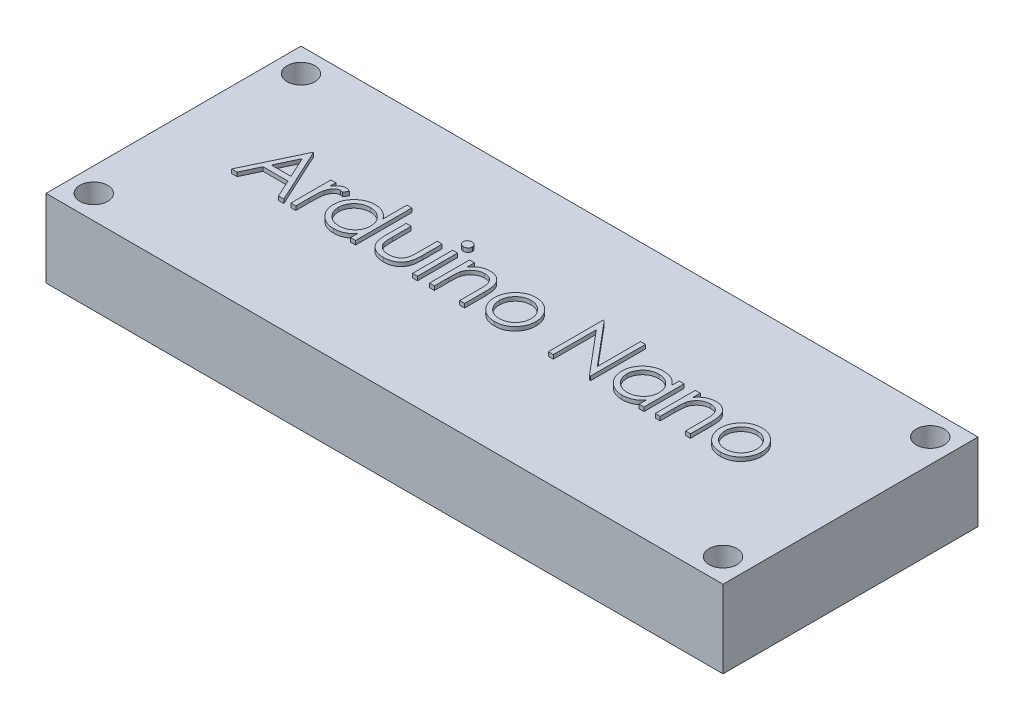
from build123d import *

# Parameters (mm, degrees)
SKETCH1_W           = 43.18
SKETCH1_H           = 16.26414524
SKETCH1_R           = 0.889
BOSS_EXTRUDE1_DEPTH = 4.953
SKETCH2_W           = 0.314102565
SKETCH2_H           = 2.557692308
BOSS_EXTRUDE2_DEPTH = 0.254


with BuildPart() as part:
    # Sketch1 → Boss-Extrude1 (new body)
    with BuildSketch(Plane(origin=(0, 0, 0), x_dir=(1, 0, 0), z_dir=(0, 1, 0))):
        Rectangle(SKETCH1_W, SKETCH1_H)
        with Locations((-20.066, 6.60807262)):
            Circle(SKETCH1_R, mode=Mode.SUBTRACT)
        with Locations((20.066, 6.60807262)):
            Circle(SKETCH1_R, mode=Mode.SUBTRACT)
        with Locations((20.066, -6.60807262)):
            Circle(SKETCH1_R, mode=Mode.SUBTRACT)
        with Locations((-20.066, -6.60807262)):
            Circle(SKETCH1_R, mode=Mode.SUBTRACT)
    extrude(amount=-BOSS_EXTRUDE1_DEPTH)

    # Sketch2 → Boss-Extrude2 (add)
    with BuildSketch(Plane(origin=(0, 0, 0), x_dir=(1, 0, 0), z_dir=(0, 1, 0))):
        Polygon((-15.054526982, 2.384665523), (-13.439142367, -1.115334477), (-13.780588681, -1.115334477), (-14.298016566, 0.006460395), (-15.884655188, 0.006460395), (-16.41680663, -1.115334477), (-16.759655188, -1.115334477), (-15.099398777, 2.384665523), align=None)
        Polygon((-15.080468489, 1.702474017), (-15.714282591, 0.365434754), (-14.463481309, 0.365434754), align=None, mode=Mode.SUBTRACT)
        with BuildLine():
            Line((-12.990424418, 1.442357831), (-12.676321854, 1.442357831))
            Line((-12.676321854, 1.442357831), (-12.676321854, 1.065855427))
            add(Edge.make_bspline(
                [(-12.676321854, 1.065855427), (-12.653133095, 1.100911255), (-12.608784775, 1.167955255), (-12.535071845, 1.256624556), (-12.459568514, 1.330039602), (-12.381913327, 1.388543121), (-12.301535227, 1.43235624), (-12.220198275, 1.464449275), (-12.136622805, 1.48342659), (-12.080460881, 1.485960249), (-12.052323457, 1.487229626)],
                knots=[0, 0, 0, 0, 0.000126023, 0.000241017, 0.000345147, 0.000441342, 0.00053171, 0.000618946, 0.000702978, 0.000787349, 0.000787349, 0.000787349, 0.000787349], degree=3))
            add(Edge.make_bspline(
                [(-12.052323457, 1.487229626), (-12.03049713, 1.486039099), (-11.985588045, 1.483589513), (-11.917605455, 1.466378689), (-11.847562003, 1.438900666), (-11.802419616, 1.413060443), (-11.778885957, 1.399589401)],
                knots=[0, 0, 0, 0, 6.5445e-05, 0.000134658, 0.00020926, 0.000290509, 0.000290509, 0.000290509, 0.000290509], degree=3))
            Line((-11.778885957, 1.399589401), (-11.951361918, 1.127554145))
            add(Edge.make_bspline(
                [(-11.951361918, 1.127554145), (-11.966470939, 1.134294411), (-11.995150754, 1.147088726), (-12.03710532, 1.162230737), (-12.075786657, 1.171146652), (-12.100430215, 1.17249737), (-12.111918809, 1.173127062)],
                knots=[0, 0, 0, 0, 4.9621e-05, 9.4191e-05, 0.00013366, 0.000168129, 0.000168129, 0.000168129, 0.000168129], degree=3))
            add(Edge.make_bspline(
                [(-12.111918809, 1.173127062), (-12.137124543, 1.171447024), (-12.188536933, 1.168020235), (-12.264021432, 1.141081427), (-12.337268638, 1.097556187), (-12.3954403, 1.049285075), (-12.440482553, 1.002737278), (-12.472622779, 0.962088875), (-12.502105525, 0.916510244), (-12.530275746, 0.86678056), (-12.55594204, 0.812050714), (-12.579896709, 0.7528675), (-12.601555572, 0.689162372), (-12.613905816, 0.644779851), (-12.620232111, 0.622045331)],
                knots=[0, 0, 0, 0, 7.549e-05, 0.000153978, 0.000237553, 0.000330197, 0.000379784, 0.000431685, 0.000485357, 0.000542493, 0.000603021, 0.000666557, 0.00073396, 0.000804745, 0.000804745, 0.000804745, 0.000804745], degree=3))
            add(Edge.make_bspline(
                [(-12.620232111, 0.622045331), (-12.624964504, 0.601768157), (-12.635446396, 0.556855759), (-12.645637934, 0.481507234), (-12.655707452, 0.392483575), (-12.66280407, 0.289536982), (-12.669382112, 0.172924538), (-12.673092194, 0.042468593), (-12.676195335, -0.101964758), (-12.676278402, -0.202939112), (-12.676321854, -0.255759156)],
                knots=[0, 0, 0, 0, 6.2435e-05, 0.000138289, 0.000227871, 0.000331224, 0.000447781, 0.000578258, 0.000722716, 0.000881171, 0.000881171, 0.000881171, 0.000881171], degree=3))
            Line((-12.676321854, -0.255759156), (-12.676321854, -1.115334477))
            Line((-12.676321854, -1.115334477), (-12.990424418, -1.115334477))
            Line((-12.990424418, -1.115334477), (-12.990424418, 1.442357831))
        make_face()
        with BuildLine():
            Line((-8.86221929, 2.474409113), (-8.86221929, -1.115334477))
            Line((-8.86221929, -1.115334477), (-9.176321854, -1.115334477))
            Line((-9.176321854, -1.115334477), (-9.176321854, -0.672926624))
            add(Edge.make_bspline(
                [(-9.176321854, -0.672926624), (-9.211740645, -0.712966218), (-9.28086086, -0.791103989), (-9.396301978, -0.893186162), (-9.518670156, -0.977564483), (-9.647371477, -1.045714399), (-9.782289721, -1.096906455), (-9.923125808, -1.133292615), (-10.069937189, -1.15668645), (-10.170189543, -1.159022472), (-10.220993329, -1.160206272)],
                knots=[0, 0, 0, 0, 0.000160263, 0.000312755, 0.000460949, 0.000605216, 0.000748578, 0.000892786, 0.001041028, 0.001193333, 0.001193333, 0.001193333, 0.001193333], degree=3))
            add(Edge.make_bspline(
                [(-10.220993329, -1.160206272), (-10.266161282, -1.158979899), (-10.355234487, -1.156561439), (-10.486263564, -1.137799135), (-10.612355814, -1.107668514), (-10.733630387, -1.065767624), (-10.849302532, -1.010186803), (-10.960362629, -0.943645555), (-11.066235321, -0.864404725), (-11.16530686, -0.773816696), (-11.25653886, -0.675421709), (-11.336600133, -0.570476162), (-11.403353213, -0.459433858), (-11.459173293, -0.343700704), (-11.502169638, -0.222385785), (-11.532143272, -0.095908617), (-11.550883719, 0.035581257), (-11.553301179, 0.12512078), (-11.554526982, 0.170522895)],
                knots=[0, 0, 0, 0, 0.000135464, 0.00026714, 0.000396211, 0.000523931, 0.000651257, 0.000780517, 0.000911767, 0.001047265, 0.00118272, 0.001313831, 0.001442491, 0.001570752, 0.001698704, 0.001827775, 0.001960146, 0.00209631, 0.00209631, 0.00209631, 0.00209631], degree=3))
            add(Edge.make_bspline(
                [(-11.554526982, 0.170522895), (-11.553274011, 0.214986599), (-11.550796954, 0.302888942), (-11.532343734, 0.43216764), (-11.501312726, 0.556685901), (-11.457764878, 0.676042844), (-11.401922923, 0.790382894), (-11.333994836, 0.899786919), (-11.253975711, 1.004556316), (-11.161723304, 1.102227543), (-11.061788534, 1.192448157), (-10.954879803, 1.270857203), (-10.843656522, 1.338574052), (-10.726393511, 1.392227528), (-10.604826407, 1.435636633), (-10.477872961, 1.465669601), (-10.346061382, 1.483366922), (-10.25657089, 1.485929686), (-10.211177623, 1.487229626)],
                knots=[0, 0, 0, 0, 0.000133363, 0.00026365, 0.000390846, 0.000517716, 0.000644083, 0.000771912, 0.000903449, 0.001038867, 0.001174416, 0.001306792, 0.001436052, 0.00156435, 0.001692963, 0.001822716, 0.001954992, 0.002091156, 0.002091156, 0.002091156, 0.002091156], degree=3))
            add(Edge.make_bspline(
                [(-10.211177623, 1.487229626), (-10.158960816, 1.48566253), (-10.056465025, 1.482586494), (-9.906566504, 1.456880127), (-9.764778893, 1.41371725), (-9.630285906, 1.354625968), (-9.503889345, 1.277825217), (-9.384662705, 1.185073769), (-9.274679382, 1.073746623), (-9.209607559, 0.99013505), (-9.176321854, 0.947365844)],
                knots=[0, 0, 0, 0, 0.000156576, 0.000307342, 0.000454614, 0.000600266, 0.00074684, 0.00089719, 0.001052366, 0.001214863, 0.001214863, 0.001214863, 0.001214863], degree=3))
            Line((-9.176321854, 0.947365844), (-9.176321854, 2.474409113))
            Line((-9.176321854, 2.474409113), (-8.86221929, 2.474409113))
        make_face()
        with BuildLine():
            add(Edge.make_bspline(
                [(-10.206970893, 1.173127062), (-10.252885231, 1.171493424), (-10.343512831, 1.168268883), (-10.476556833, 1.143095388), (-10.603870247, 1.101210793), (-10.724816321, 1.043928892), (-10.837484538, 0.971900156), (-10.938178208, 0.884778772), (-11.02772091, 0.784941758), (-11.103029174, 0.672839648), (-11.164419671, 0.552661557), (-11.207586703, 0.427037119), (-11.23605595, 0.298232141), (-11.238964471, 0.210869455), (-11.240424418, 0.167017286)],
                knots=[0, 0, 0, 0, 0.000137677, 0.000271753, 0.000404561, 0.000538791, 0.000672205, 0.000804452, 0.00093703, 0.001073348, 0.00120849, 0.001340643, 0.001470999, 0.001602378, 0.001602378, 0.001602378, 0.001602378], degree=3))
            add(Edge.make_bspline(
                [(-11.240424418, 0.167017286), (-11.238559525, 0.123427179), (-11.234837048, 0.036417823), (-11.208086354, -0.092562754), (-11.16320648, -0.218216796), (-11.101964418, -0.339477789), (-11.025277793, -0.45206189), (-10.93638914, -0.553802012), (-10.834438859, -0.641291601), (-10.721511352, -0.714529174), (-10.600903382, -0.773691695), (-10.47406945, -0.814857335), (-10.343393812, -0.841435115), (-10.254541478, -0.844539592), (-10.20977538, -0.846103708)],
                knots=[0, 0, 0, 0, 0.000130727, 0.000260941, 0.000393327, 0.000530037, 0.000667328, 0.000800955, 0.000934191, 0.001068956, 0.001203792, 0.001335934, 0.001468075, 0.001602253, 0.001602253, 0.001602253, 0.001602253], degree=3))
            add(Edge.make_bspline(
                [(-10.20977538, -0.846103708), (-10.164328877, -0.844443744), (-10.073940291, -0.84114224), (-9.940501583, -0.815860975), (-9.81100662, -0.774092176), (-9.687219392, -0.71619305), (-9.57190326, -0.644435694), (-9.468405383, -0.560428603), (-9.380889414, -0.462725419), (-9.306696805, -0.355348966), (-9.248521388, -0.237636969), (-9.206145329, -0.112302778), (-9.181091423, 0.02065797), (-9.177933694, 0.111521897), (-9.176321854, 0.157902703)],
                knots=[0, 0, 0, 0, 0.000136278, 0.000271043, 0.000405851, 0.000543552, 0.000679927, 0.000812429, 0.000941985, 0.001072088, 0.00120284, 0.001334538, 0.001467925, 0.001607002, 0.001607002, 0.001607002, 0.001607002], degree=3))
            add(Edge.make_bspline(
                [(-9.176321854, 0.157902703), (-9.177281511, 0.193240533), (-9.179170418, 0.262796567), (-9.193600988, 0.364924084), (-9.216555914, 0.46265781), (-9.248902084, 0.556100499), (-9.291393368, 0.644735515), (-9.342641134, 0.729199275), (-9.403546584, 0.809052486), (-9.47312928, 0.883195557), (-9.549294483, 0.950822019), (-9.629889023, 1.01118626), (-9.71586777, 1.060775033), (-9.805784807, 1.101816304), (-9.899796142, 1.134475454), (-9.998666761, 1.156263148), (-10.101345748, 1.171223469), (-10.171391804, 1.17248585), (-10.206970893, 1.173127062)],
                knots=[0, 0, 0, 0, 0.000105983, 0.000208608, 0.000308773, 0.00040678, 0.000504626, 0.000603105, 0.000702667, 0.00080535, 0.000907651, 0.001007914, 0.001106881, 0.00120477, 0.001304102, 0.001404791, 0.00150811, 0.001614764, 0.001614764, 0.001614764, 0.001614764], degree=3))
        make_face(mode=Mode.SUBTRACT)
        with BuildLine():
            Line((-8.189142367, 1.442357831), (-7.875039803, 1.442357831))
            Line((-7.875039803, 1.442357831), (-7.875039803, 0.256059754))
            add(Edge.make_bspline(
                [(-7.875039803, 0.256059754), (-7.874897898, 0.221237005), (-7.874626441, 0.154622717), (-7.8727855, 0.05876753), (-7.868455406, -0.028649183), (-7.863041582, -0.107677919), (-7.856079445, -0.178305311), (-7.847796085, -0.240284668), (-7.838537663, -0.294318852), (-7.829474949, -0.326862208), (-7.825260156, -0.341997137)],
                knots=[0, 0, 0, 0, 0.00010447, 0.000199845, 0.000287586, 0.000367011, 0.000437473, 0.000500438, 0.00055462, 0.000601725, 0.000601725, 0.000601725, 0.000601725], degree=3))
            add(Edge.make_bspline(
                [(-7.825260156, -0.341997137), (-7.818498701, -0.361020008), (-7.805116359, -0.398670269), (-7.780842876, -0.453059274), (-7.750814539, -0.503434557), (-7.717954711, -0.55173863), (-7.680055304, -0.596540616), (-7.637595833, -0.63776486), (-7.591997596, -0.676968951), (-7.524242572, -0.723353743), (-7.431583306, -0.773069073), (-7.309930551, -0.815964892), (-7.178026325, -0.841600712), (-7.086861606, -0.844574967), (-7.040003745, -0.846103708)],
                knots=[0, 0, 0, 0, 6.0561e-05, 0.000119863, 0.000178304, 0.000236261, 0.000294971, 0.000353969, 0.000413668, 0.000475127, 0.000599968, 0.00072792, 0.000860749, 0.001001226, 0.001001226, 0.001001226, 0.001001226], degree=3))
            add(Edge.make_bspline(
                [(-7.040003745, -0.846103708), (-6.993150238, -0.844542459), (-6.902497369, -0.841521732), (-6.7720424, -0.816738193), (-6.652790986, -0.775332504), (-6.545940034, -0.717525092), (-6.451974194, -0.64678303), (-6.373669775, -0.563774221), (-6.309062521, -0.471124834), (-6.2808531, -0.402000555), (-6.266666406, -0.367237522)],
                knots=[0, 0, 0, 0, 0.000140477, 0.000271796, 0.000396637, 0.000517726, 0.000634816, 0.00074789, 0.000858929, 0.000971266, 0.000971266, 0.000971266, 0.000971266], degree=3))
            add(Edge.make_bspline(
                [(-6.266666406, -0.367237522), (-6.262472175, -0.353271223), (-6.253199757, -0.322395148), (-6.243237406, -0.270015399), (-6.234262944, -0.207550795), (-6.226599768, -0.134592586), (-6.221134605, -0.051331434), (-6.218188579, 0.042206643), (-6.214860303, 0.145728003), (-6.214809787, 0.218195762), (-6.214783393, 0.256059754)],
                knots=[0, 0, 0, 0, 4.3723e-05, 9.6661e-05, 0.000159723, 0.000233047, 0.000316669, 0.000409984, 0.000513788, 0.000627372, 0.000627372, 0.000627372, 0.000627372], degree=3))
            Line((-6.214783393, 0.256059754), (-6.214783393, 1.442357831))
            Line((-6.214783393, 1.442357831), (-5.900680829, 1.442357831))
            Line((-5.900680829, 1.442357831), (-5.900680829, 0.197165523))
            add(Edge.make_bspline(
                [(-5.900680829, 0.197165523), (-5.901122523, 0.154858352), (-5.901979472, 0.072776652), (-5.907486815, -0.04650746), (-5.916936428, -0.157669705), (-5.931279113, -0.260768924), (-5.948144788, -0.355726406), (-5.96990106, -0.442663852), (-5.995879298, -0.521313406), (-6.025184813, -0.593055183), (-6.059806681, -0.658102077), (-6.096633701, -0.719837894), (-6.139158473, -0.776730829), (-6.183928707, -0.831612966), (-6.233730363, -0.881754494), (-6.287630222, -0.928305969), (-6.344869642, -0.971979001), (-6.40671884, -1.011070281), (-6.472274903, -1.046286926), (-6.54161876, -1.077503004), (-6.615599758, -1.102205581), (-6.693263395, -1.123516247), (-6.774990174, -1.140230716), (-6.860701308, -1.152017283), (-6.950367924, -1.159242614), (-7.011477383, -1.159879659), (-7.042808232, -1.160206272)],
                knots=[0, 0, 0, 0, 0.00012692, 0.000246243, 0.000358153, 0.000461473, 0.000558423, 0.000647357, 0.000730057, 0.000806749, 0.000879504, 0.000950929, 0.001022168, 0.001092368, 0.001163264, 0.001233837, 0.001305913, 0.001379045, 0.001453076, 0.001529034, 0.001606858, 0.001686798, 0.001770538, 0.001856901, 0.001946219, 0.002040193, 0.002040193, 0.002040193, 0.002040193], degree=3))
            add(Edge.make_bspline(
                [(-7.042808232, -1.160206272), (-7.073904747, -1.159866565), (-7.135012292, -1.159199008), (-7.224683536, -1.152057201), (-7.310632142, -1.14024903), (-7.392552541, -1.123393813), (-7.470526938, -1.102354743), (-7.544871178, -1.077351207), (-7.614714741, -1.046270726), (-7.680896745, -1.011293168), (-7.742899133, -0.971727893), (-7.801007711, -0.928359853), (-7.855144564, -0.88125379), (-7.905321632, -0.830606433), (-7.950834608, -0.775789496), (-7.99225065, -0.717243936), (-8.030207355, -0.655549848), (-8.064560146, -0.589486685), (-8.094071901, -0.516914675), (-8.120127147, -0.436617578), (-8.141437785, -0.347715061), (-8.158780254, -0.250283133), (-8.172731694, -0.144788091), (-8.182417837, -0.030619676), (-8.187833667, 0.091944016), (-8.188696729, 0.176593906), (-8.189142367, 0.220302542)],
                knots=[0, 0, 0, 0, 9.3273e-05, 0.00018329, 0.000269653, 0.000353393, 0.000434009, 0.000511834, 0.000588433, 0.000663082, 0.000736214, 0.00080885, 0.000880413, 0.000951309, 0.001022496, 0.001093894, 0.001166283, 0.00123966, 0.001317, 0.001401032, 0.001492689, 0.001591018, 0.001697812, 0.001811817, 0.001934642, 0.002065769, 0.002065769, 0.002065769, 0.002065769], degree=3))
            Line((-8.189142367, 0.220302542), (-8.189142367, 1.442357831))
        make_face()
        with BuildLine():
            add(Edge.make_bspline(
                [(-5.071954867, 2.519280908), (-5.052463551, 2.518376755), (-5.014295811, 2.516606251), (-4.959102544, 2.501444774), (-4.908845532, 2.475745089), (-4.864267799, 2.441265408), (-4.826015912, 2.400715964), (-4.799235202, 2.353454996), (-4.782022806, 2.302396357), (-4.77994425, 2.266781268), (-4.778885957, 2.248647895)],
                knots=[0, 0, 0, 0, 5.84e-05, 0.000114358, 0.000170171, 0.000226684, 0.000282761, 0.000336156, 0.000388483, 0.00044276, 0.00044276, 0.00044276, 0.00044276], degree=3))
            add(Edge.make_bspline(
                [(-4.778885957, 2.248647895), (-4.779968117, 2.230985242), (-4.782107419, 2.196068267), (-4.799221907, 2.145894795), (-4.826244145, 2.099290511), (-4.86424327, 2.058819801), (-4.908852031, 2.024359181), (-4.959100817, 1.998654442), (-5.014296266, 1.983494305), (-5.052463705, 1.981723616), (-5.071954867, 1.980819369)],
                knots=[0, 0, 0, 0, 5.2882e-05, 0.000104542, 0.000157332, 0.000213408, 0.000269922, 0.000325735, 0.000381693, 0.000440092, 0.000440092, 0.000440092, 0.000440092], degree=3))
            add(Edge.make_bspline(
                [(-5.071954867, 1.980819369), (-5.091223142, 1.98168909), (-5.128726322, 1.983381886), (-5.183093165, 1.998951904), (-5.232921654, 2.024367977), (-5.277586327, 2.058594162), (-5.31481652, 2.099539059), (-5.341914845, 2.145866353), (-5.358989807, 2.196075508), (-5.361134436, 2.230987674), (-5.36221929, 2.248647895)],
                knots=[0, 0, 0, 0, 5.7701e-05, 0.000112308, 0.000168121, 0.000224634, 0.000280239, 0.000333029, 0.000384689, 0.000437571, 0.000437571, 0.000437571, 0.000437571], degree=3))
            add(Edge.make_bspline(
                [(-5.36221929, 2.248647895), (-5.361158204, 2.266778745), (-5.359074162, 2.302388877), (-5.341902046, 2.35348391), (-5.315042239, 2.400465412), (-5.277561675, 2.441490911), (-5.232928215, 2.475736346), (-5.18309147, 2.501147328), (-5.12872677, 2.516718667), (-5.091223294, 2.518411281), (-5.071954867, 2.519280908)],
                knots=[0, 0, 0, 0, 5.4277e-05, 0.000106603, 0.000159999, 0.000215605, 0.000272118, 0.000327931, 0.000382538, 0.000440239, 0.000440239, 0.000440239, 0.000440239], degree=3))
        make_face()
        with Locations((-5.070552624, 0.163511677)):
            Rectangle(SKETCH2_W, SKETCH2_H)
        with BuildLine():
            Line((-4.150680829, 1.442357831), (-3.836578265, 1.442357831))
            Line((-3.836578265, 1.442357831), (-3.836578265, 0.98101969))
            add(Edge.make_bspline(
                [(-3.836578265, 0.98101969), (-3.803040629, 1.022862413), (-3.737959678, 1.104059676), (-3.629575345, 1.210780251), (-3.515031445, 1.298725476), (-3.395029441, 1.36882927), (-3.269406431, 1.421675896), (-3.138928161, 1.459841827), (-3.002813455, 1.482726655), (-2.910249018, 1.485716886), (-2.863421213, 1.487229626)],
                knots=[0, 0, 0, 0, 0.000160777, 0.000311994, 0.000455029, 0.000592958, 0.000727738, 0.000862858, 0.001000022, 0.001140458, 0.001140458, 0.001140458, 0.001140458], degree=3))
            add(Edge.make_bspline(
                [(-2.863421213, 1.487229626), (-2.816090579, 1.48548443), (-2.723453111, 1.482068662), (-2.58857505, 1.455051971), (-2.462601656, 1.408906716), (-2.3459821, 1.345694645), (-2.240854887, 1.267088172), (-2.148530036, 1.17551039), (-2.072166788, 1.070174307), (-2.020969425, 0.972451151), (-1.987243778, 0.885762356), (-1.96601144, 0.811515606), (-1.947980459, 0.728797455), (-1.932348711, 0.637857866), (-1.921771599, 0.538059676), (-1.913429307, 0.429811984), (-1.907450613, 0.313149853), (-1.907213406, 0.232463226), (-1.907091085, 0.190855427)],
                knots=[0, 0, 0, 0, 0.00014192, 0.000277771, 0.000410631, 0.000543023, 0.000674273, 0.000803173, 0.000931629, 0.001063031, 0.00113295, 0.001210382, 0.001294414, 0.001386856, 0.001487045, 0.001595345, 0.001712567, 0.001837375, 0.001837375, 0.001837375, 0.001837375], degree=3))
            Line((-1.907091085, 0.190855427), (-1.907091085, -1.115334477))
            Line((-1.907091085, -1.115334477), (-2.221193649, -1.115334477))
            Line((-2.221193649, -1.115334477), (-2.221193649, 0.087790523))
            add(Edge.make_bspline(
                [(-2.221193649, 0.087790523), (-2.221386857, 0.122612968), (-2.221756431, 0.189222379), (-2.222922078, 0.284591402), (-2.225731884, 0.37107798), (-2.229680197, 0.448475348), (-2.235459228, 0.516709184), (-2.241481859, 0.575918461), (-2.248846836, 0.626028004), (-2.255409749, 0.656193086), (-2.258353104, 0.669721613)],
                knots=[0, 0, 0, 0, 0.00010447, 0.000199832, 0.000286116, 0.000364054, 0.000432294, 0.000491525, 0.000542592, 0.000584118, 0.000584118, 0.000584118, 0.000584118], degree=3))
            add(Edge.make_bspline(
                [(-2.258353104, 0.669721613), (-2.268978636, 0.709432798), (-2.289429496, 0.785864542), (-2.33996348, 0.889538895), (-2.40377766, 0.977737083), (-2.48167551, 1.049913805), (-2.572904585, 1.106084641), (-2.677211728, 1.145058596), (-2.793590369, 1.169434865), (-2.875444751, 1.171861997), (-2.918108713, 1.173127062)],
                knots=[0, 0, 0, 0, 0.000123096, 0.000236922, 0.000343781, 0.000447968, 0.000553428, 0.000663063, 0.000780492, 0.000908329, 0.000908329, 0.000908329, 0.000908329], degree=3))
            add(Edge.make_bspline(
                [(-2.918108713, 1.173127062), (-2.943376397, 1.172651057), (-2.99338049, 1.171709056), (-3.067530462, 1.162257758), (-3.139454635, 1.146799302), (-3.209874844, 1.125930665), (-3.277382638, 1.097268396), (-3.344146929, 1.064739025), (-3.407653693, 1.024190813), (-3.46925709, 0.979000192), (-3.526569898, 0.928920985), (-3.579898236, 0.876076475), (-3.627436256, 0.819800871), (-3.670504932, 0.761000923), (-3.707683195, 0.698869085), (-3.740136283, 0.634004779), (-3.767671978, 0.56632263), (-3.78135467, 0.519347569), (-3.788200861, 0.495843408)],
                knots=[0, 0, 0, 0, 7.5773e-05, 0.000149953, 0.000223797, 0.000296325, 0.00036989, 0.000443574, 0.000518859, 0.000595564, 0.000672601, 0.000746967, 0.000820581, 0.000893366, 0.000965391, 0.001037508, 0.001110807, 0.001184211, 0.001184211, 0.001184211, 0.001184211], degree=3))
            add(Edge.make_bspline(
                [(-3.788200861, 0.495843408), (-3.792140509, 0.478588205), (-3.800716918, 0.44102453), (-3.809980098, 0.379380111), (-3.818387673, 0.308070136), (-3.825424632, 0.227177819), (-3.829730048, 0.136419944), (-3.834424445, 0.036184106), (-3.836133506, -0.073929382), (-3.83642586, -0.150591075), (-3.836578265, -0.190554829)],
                knots=[0, 0, 0, 0, 5.3082e-05, 0.000115557, 0.000186868, 0.0002685, 0.000359077, 0.000459426, 0.000569522, 0.000689416, 0.000689416, 0.000689416, 0.000689416], degree=3))
            Line((-3.836578265, -0.190554829), (-3.836578265, -1.115334477))
            Line((-3.836578265, -1.115334477), (-4.150680829, -1.115334477))
            Line((-4.150680829, -1.115334477), (-4.150680829, 1.442357831))
        make_face()
        with BuildLine():
            add(Edge.make_bspline(
                [(0.046234235, 1.487229626), (0.094225508, 1.486207735), (0.188324666, 1.484204056), (0.326132552, 1.46278909), (0.457677688, 1.430041726), (0.58346388, 1.384770164), (0.701880175, 1.324088213), (0.814651419, 1.251678922), (0.921468428, 1.165896328), (0.985491458, 1.09953826), (1.017989043, 1.065855427)],
                knots=[0, 0, 0, 0, 0.000143868, 0.000282091, 0.000417278, 0.000550139, 0.000682145, 0.000815559, 0.000951665, 0.001091969, 0.001091969, 0.001091969, 0.001091969], degree=3))
            add(Edge.make_bspline(
                [(1.017989043, 1.065855427), (1.045970997, 1.033641441), (1.101393377, 0.969836899), (1.172459096, 0.866381286), (1.233680656, 0.759241185), (1.282743617, 0.646993859), (1.321428641, 0.530619188), (1.348894337, 0.409717176), (1.365231272, 0.284554829), (1.367434239, 0.199550991), (1.368549941, 0.156500459)],
                knots=[0, 0, 0, 0, 0.000127922, 0.000253368, 0.000375813, 0.000497617, 0.000620225, 0.000743195, 0.000869033, 0.000998161, 0.000998161, 0.000998161, 0.000998161], degree=3))
            add(Edge.make_bspline(
                [(1.368549941, 0.156500459), (1.367568603, 0.113200401), (1.365629435, 0.027637468), (1.347285819, -0.098381898), (1.318754733, -0.22057672), (1.277922895, -0.338435414), (1.225564785, -0.452318242), (1.161674098, -0.561727791), (1.085802481, -0.666879924), (0.999798484, -0.766881762), (0.904746608, -0.859047977), (0.801630459, -0.939376247), (0.692476426, -1.008197771), (0.575833072, -1.063634187), (0.452765586, -1.107343887), (0.323008517, -1.138043903), (0.186763447, -1.156605587), (0.093736226, -1.158989161), (0.046234235, -1.160206272)],
                knots=[0, 0, 0, 0, 0.000129829, 0.000256548, 0.000381202, 0.000505812, 0.000630045, 0.000756669, 0.000885282, 0.001018518, 0.001151902, 0.001281775, 0.001409974, 0.001538236, 0.001668405, 0.001801048, 0.001937587, 0.002080055, 0.002080055, 0.002080055, 0.002080055], degree=3))
            add(Edge.make_bspline(
                [(0.046234235, -1.160206272), (-0.001500484, -1.158985075), (-0.094991344, -1.156593301), (-0.231717326, -1.138116018), (-0.361706945, -1.107358036), (-0.484935543, -1.063490543), (-0.60208039, -1.008195999), (-0.711866887, -0.93958431), (-0.815066803, -0.859024154), (-0.910138787, -0.766888217), (-0.996137392, -0.666878261), (-1.072010401, -0.561728223), (-1.135900727, -0.452318129), (-1.188258931, -0.338435444), (-1.229090744, -0.220576712), (-1.257621836, -0.0983819), (-1.275965451, 0.027637469), (-1.277904619, 0.113200402), (-1.278885957, 0.156500459)],
                knots=[0, 0, 0, 0, 0.000143168, 0.000280402, 0.000413045, 0.000543214, 0.000672108, 0.000800903, 0.000930775, 0.00106416, 0.001197395, 0.001326009, 0.001452632, 0.001576866, 0.001701476, 0.00182613, 0.001952849, 0.002082678, 0.002082678, 0.002082678, 0.002082678], degree=3))
            add(Edge.make_bspline(
                [(-1.278885957, 0.156500459), (-1.277762646, 0.199317005), (-1.275538685, 0.284086407), (-1.259218176, 0.409013468), (-1.231859619, 0.529710857), (-1.193128223, 0.645636333), (-1.143613032, 0.757391769), (-1.083251744, 0.8647966), (-1.011461112, 0.967784401), (-0.95625916, 1.031506481), (-0.928325059, 1.063752062)],
                knots=[0, 0, 0, 0, 0.000128428, 0.000254265, 0.000377235, 0.000499178, 0.000620341, 0.000743397, 0.000868267, 0.000996189, 0.000996189, 0.000996189, 0.000996189], degree=3))
            add(Edge.make_bspline(
                [(-0.928325059, 1.063752062), (-0.895876468, 1.097727001), (-0.832060604, 1.164544697), (-0.724711877, 1.250077221), (-0.612218056, 1.323993295), (-0.49249313, 1.38346951), (-0.366810272, 1.430308028), (-0.234591029, 1.462873543), (-0.096315514, 1.484126898), (-0.001755892, 1.486185076), (0.046234235, 1.487229626)],
                knots=[0, 0, 0, 0, 0.000140798, 0.000276904, 0.000410699, 0.000543958, 0.000677061, 0.000812248, 0.000951858, 0.001095726, 0.001095726, 0.001095726, 0.001095726], degree=3))
        make_face()
        with BuildLine():
            add(Edge.make_bspline(
                [(0.044831992, 1.173127062), (0.010894381, 1.17216247), (-0.056104748, 1.170258187), (-0.154724333, 1.155774283), (-0.249664487, 1.132826779), (-0.341105331, 1.100222722), (-0.428738503, 1.058123823), (-0.512647906, 1.006415463), (-0.593080346, 0.945782507), (-0.668462409, 0.876319835), (-0.737644721, 0.800440841), (-0.798122698, 0.719592482), (-0.849547804, 0.635086135), (-0.892387963, 0.546833924), (-0.924295151, 0.45394151), (-0.947468174, 0.357460879), (-0.961938414, 0.257195463), (-0.963824793, 0.189034444), (-0.964783393, 0.154397094)],
                knots=[0, 0, 0, 0, 0.000101781, 0.000200935, 0.000298373, 0.000394396, 0.000491609, 0.000589491, 0.000689611, 0.000793323, 0.000896562, 0.000997243, 0.001095722, 0.001192936, 0.001290943, 0.001389744, 0.001490285, 0.001594167, 0.001594167, 0.001594167, 0.001594167], degree=3))
            add(Edge.make_bspline(
                [(-0.964783393, 0.154397094), (-0.963176569, 0.109645067), (-0.959987325, 0.020820661), (-0.934052088, -0.109990462), (-0.890665808, -0.235572314), (-0.832078529, -0.3551887), (-0.75867231, -0.465860978), (-0.672185243, -0.564532462), (-0.573545543, -0.649718274), (-0.463929043, -0.720399119), (-0.345574725, -0.776558875), (-0.220318404, -0.816357851), (-0.08967771, -0.842229543), (-0.000396978, -0.844801017), (0.044831992, -0.846103708)],
                knots=[0, 0, 0, 0, 0.000134178, 0.000266319, 0.000398243, 0.00053182, 0.000664828, 0.000795487, 0.000924236, 0.001054533, 0.001185628, 0.001316003, 0.001448011, 0.001583547, 0.001583547, 0.001583547, 0.001583547], degree=3))
            add(Edge.make_bspline(
                [(0.044831992, -0.846103708), (0.090058361, -0.844793427), (0.179333957, -0.84220697), (0.309793134, -0.816488151), (0.434707106, -0.77638449), (0.552938493, -0.72046228), (0.662505096, -0.649449865), (0.761854218, -0.565013488), (0.847602829, -0.465599637), (0.920936434, -0.355042108), (0.980483177, -0.235757756), (1.023666378, -0.109967284), (1.049663964, 0.020814758), (1.052844793, 0.109643089), (1.054447377, 0.154397094)],
                knots=[0, 0, 0, 0, 0.000135536, 0.000267545, 0.000397252, 0.000528347, 0.000658644, 0.000787925, 0.000918122, 0.00105113, 0.001185017, 0.001316942, 0.001449082, 0.00158326, 0.00158326, 0.00158326, 0.00158326], degree=3))
            add(Edge.make_bspline(
                [(1.054447377, 0.154397094), (1.053489106, 0.189034651), (1.051603377, 0.257196077), (1.037128413, 0.357458531), (1.013972873, 0.453950127), (0.982001256, 0.546802131), (0.939347242, 0.635314635), (0.886930449, 0.719344362), (0.826699424, 0.800720908), (0.756682303, 0.876074549), (0.681378925, 0.945809585), (0.600913887, 1.006438975), (0.517128908, 1.05789657), (0.429750326, 1.100582811), (0.338297758, 1.132530151), (0.243490629, 1.155906783), (0.145291819, 1.170196979), (0.078532776, 1.172144121), (0.044831992, 1.173127062)],
                knots=[0, 0, 0, 0, 0.000103882, 0.000204424, 0.000303225, 0.000401232, 0.000498445, 0.000597291, 0.000697972, 0.000801684, 0.000905395, 0.001005516, 0.001103397, 0.001199979, 0.001296663, 0.00139342, 0.001492573, 0.001593654, 0.001593654, 0.001593654, 0.001593654], degree=3))
        make_face(mode=Mode.SUBTRACT)
        Polygon((3.432652505, -1.115334477), (3.432652505, 2.384665523), (3.498557953, 2.384665523), (5.810857633, -0.370042009), (5.810857633, 2.384665523), (6.124960197, 2.384665523), (6.124960197, -1.115334477), (6.053445774, -1.115334477), (3.746755069, 1.633062959), (3.746755069, -1.115334477), align=None)
        with BuildLine():
            Line((9.535216607, 1.442357831), (9.535216607, -1.115334477))
            Line((9.535216607, -1.115334477), (9.221114043, -1.115334477))
            Line((9.221114043, -1.115334477), (9.221114043, -0.672926624))
            add(Edge.make_bspline(
                [(9.221114043, -0.672926624), (9.185695253, -0.712966218), (9.116575037, -0.791103989), (9.001133919, -0.893186162), (8.878765741, -0.977564483), (8.75006442, -1.045714399), (8.615146177, -1.096906455), (8.47431009, -1.133292615), (8.327498709, -1.15668645), (8.227246354, -1.159022472), (8.176442569, -1.160206272)],
                knots=[0, 0, 0, 0, 0.000160263, 0.000312755, 0.000460949, 0.000605216, 0.000748578, 0.000892786, 0.001041028, 0.001193333, 0.001193333, 0.001193333, 0.001193333], degree=3))
            add(Edge.make_bspline(
                [(8.176442569, -1.160206272), (8.131274615, -1.158979899), (8.04220141, -1.156561439), (7.911172333, -1.137799135), (7.785080084, -1.107668514), (7.663805511, -1.065767624), (7.548133365, -1.010186803), (7.437073269, -0.943645555), (7.331200577, -0.864404725), (7.232129038, -0.773816696), (7.140897037, -0.675421709), (7.060835765, -0.570476162), (6.994082685, -0.459433858), (6.938262604, -0.343700704), (6.89526626, -0.222385785), (6.865292626, -0.095908617), (6.846552179, 0.035581257), (6.844134718, 0.12512078), (6.842908915, 0.170522895)],
                knots=[0, 0, 0, 0, 0.000135464, 0.00026714, 0.000396211, 0.000523931, 0.000651257, 0.000780517, 0.000911767, 0.001047265, 0.00118272, 0.001313831, 0.001442491, 0.001570752, 0.001698704, 0.001827775, 0.001960146, 0.00209631, 0.00209631, 0.00209631, 0.00209631], degree=3))
            add(Edge.make_bspline(
                [(6.842908915, 0.170522895), (6.844161886, 0.214986599), (6.846638943, 0.302888942), (6.865092163, 0.43216764), (6.896123172, 0.556685901), (6.939671019, 0.676042844), (6.995512974, 0.790382894), (7.063441061, 0.899786919), (7.143460186, 1.004556316), (7.235712593, 1.102227543), (7.335647363, 1.192448157), (7.442556094, 1.270857203), (7.553779375, 1.338574052), (7.671042386, 1.392227528), (7.792609491, 1.435636633), (7.919562937, 1.465669601), (8.051374515, 1.483366922), (8.140865007, 1.485929686), (8.186258274, 1.487229626)],
                knots=[0, 0, 0, 0, 0.000133363, 0.00026365, 0.000390846, 0.000517716, 0.000644083, 0.000771912, 0.000903449, 0.001038867, 0.001174416, 0.001306792, 0.001436052, 0.00156435, 0.001692963, 0.001822716, 0.001954992, 0.002091156, 0.002091156, 0.002091156, 0.002091156], degree=3))
            add(Edge.make_bspline(
                [(8.186258274, 1.487229626), (8.238458133, 1.485791874), (8.340819593, 1.482972511), (8.490547602, 1.459509784), (8.63219208, 1.419871317), (8.766846432, 1.365953819), (8.894027118, 1.29430509), (9.012530103, 1.203925129), (9.123595586, 1.095383942), (9.187975878, 1.012013497), (9.221114043, 0.969100619)],
                knots=[0, 0, 0, 0, 0.00015654, 0.000306968, 0.000453261, 0.000596998, 0.000741098, 0.000889738, 0.001042937, 0.001205434, 0.001205434, 0.001205434, 0.001205434], degree=3))
            Line((9.221114043, 0.969100619), (9.221114043, 1.442357831))
            Line((9.221114043, 1.442357831), (9.535216607, 1.442357831))
        make_face()
        with BuildLine():
            add(Edge.make_bspline(
                [(8.190465005, 1.173127062), (8.144550667, 1.171493424), (8.053923067, 1.168268883), (7.920879065, 1.143095388), (7.793565651, 1.101210793), (7.672619576, 1.043928892), (7.55995136, 0.971900156), (7.459257689, 0.884778772), (7.369714988, 0.784941758), (7.294406723, 0.672839648), (7.233016227, 0.552661557), (7.189849195, 0.427037119), (7.161379947, 0.298232141), (7.158471427, 0.210869455), (7.157011479, 0.167017286)],
                knots=[0, 0, 0, 0, 0.000137677, 0.000271753, 0.000404561, 0.000538791, 0.000672205, 0.000804452, 0.00093703, 0.001073348, 0.00120849, 0.001340643, 0.001470999, 0.001602378, 0.001602378, 0.001602378, 0.001602378], degree=3))
            add(Edge.make_bspline(
                [(7.157011479, 0.167017286), (7.158876372, 0.123427179), (7.162598849, 0.036417823), (7.189349544, -0.092562754), (7.234229417, -0.218216796), (7.29547148, -0.339477789), (7.372158105, -0.45206189), (7.461046757, -0.553802012), (7.562997038, -0.641291601), (7.675924545, -0.714529174), (7.796532516, -0.773691695), (7.923366447, -0.814857335), (8.054042086, -0.841435115), (8.142894419, -0.844539592), (8.187660518, -0.846103708)],
                knots=[0, 0, 0, 0, 0.000130727, 0.000260941, 0.000393327, 0.000530037, 0.000667328, 0.000800955, 0.000934191, 0.001068956, 0.001203792, 0.001335934, 0.001468075, 0.001602253, 0.001602253, 0.001602253, 0.001602253], degree=3))
            add(Edge.make_bspline(
                [(8.187660518, -0.846103708), (8.23310702, -0.844443744), (8.323495607, -0.84114224), (8.456934315, -0.815860975), (8.586429278, -0.774092176), (8.710216506, -0.71619305), (8.825532637, -0.644435694), (8.929030515, -0.560428603), (9.016546483, -0.462725419), (9.090739093, -0.355348966), (9.148914509, -0.237636969), (9.191290569, -0.112302778), (9.216344474, 0.02065797), (9.219502204, 0.111521897), (9.221114043, 0.157902703)],
                knots=[0, 0, 0, 0, 0.000136278, 0.000271043, 0.000405851, 0.000543552, 0.000679927, 0.000812429, 0.000941985, 0.001072088, 0.00120284, 0.001334538, 0.001467925, 0.001607002, 0.001607002, 0.001607002, 0.001607002], degree=3))
            add(Edge.make_bspline(
                [(9.221114043, 0.157902703), (9.220154387, 0.193240533), (9.218265479, 0.262796567), (9.20383491, 0.364924084), (9.180879983, 0.46265781), (9.148533813, 0.556100499), (9.106042529, 0.644735515), (9.054794763, 0.729199275), (8.993889313, 0.809052486), (8.924306617, 0.883195557), (8.848141415, 0.950822019), (8.767546874, 1.01118626), (8.681568127, 1.060775033), (8.59165109, 1.101816304), (8.497639756, 1.134475454), (8.398769136, 1.156263148), (8.296090149, 1.171223469), (8.226044094, 1.17248585), (8.190465005, 1.173127062)],
                knots=[0, 0, 0, 0, 0.000105983, 0.000208608, 0.000308773, 0.00040678, 0.000504626, 0.000603105, 0.000702667, 0.00080535, 0.000907651, 0.001007914, 0.001106881, 0.00120477, 0.001304102, 0.001404791, 0.00150811, 0.001614764, 0.001614764, 0.001614764, 0.001614764], degree=3))
        make_face(mode=Mode.SUBTRACT)
        with BuildLine():
            Line((10.253165325, 1.442357831), (10.567267889, 1.442357831))
            Line((10.567267889, 1.442357831), (10.567267889, 0.98101969))
            add(Edge.make_bspline(
                [(10.567267889, 0.98101969), (10.600805524, 1.022862413), (10.665886476, 1.104059676), (10.774270809, 1.210780251), (10.888814709, 1.298725476), (11.008816713, 1.36882927), (11.134439723, 1.421675896), (11.264917993, 1.459841827), (11.401032699, 1.482726655), (11.493597136, 1.485716886), (11.540424941, 1.487229626)],
                knots=[0, 0, 0, 0, 0.000160777, 0.000311994, 0.000455029, 0.000592958, 0.000727738, 0.000862858, 0.001000022, 0.001140458, 0.001140458, 0.001140458, 0.001140458], degree=3))
            add(Edge.make_bspline(
                [(11.540424941, 1.487229626), (11.587755575, 1.48548443), (11.680393043, 1.482068662), (11.815271104, 1.455051971), (11.941244498, 1.408906716), (12.057864053, 1.345694645), (12.162991267, 1.267088172), (12.255316118, 1.17551039), (12.331679366, 1.070174307), (12.382876729, 0.972451151), (12.416602376, 0.885762356), (12.437834714, 0.811515606), (12.455865695, 0.728797455), (12.471497443, 0.637857866), (12.482074555, 0.538059676), (12.490416847, 0.429811984), (12.496395541, 0.313149853), (12.496632748, 0.232463226), (12.496755069, 0.190855427)],
                knots=[0, 0, 0, 0, 0.00014192, 0.000277771, 0.000410631, 0.000543023, 0.000674273, 0.000803173, 0.000931629, 0.001063031, 0.00113295, 0.001210382, 0.001294414, 0.001386856, 0.001487045, 0.001595345, 0.001712567, 0.001837375, 0.001837375, 0.001837375, 0.001837375], degree=3))
            Line((12.496755069, 0.190855427), (12.496755069, -1.115334477))
            Line((12.496755069, -1.115334477), (12.182652505, -1.115334477))
            Line((12.182652505, -1.115334477), (12.182652505, 0.087790523))
            add(Edge.make_bspline(
                [(12.182652505, 0.087790523), (12.182459297, 0.122612968), (12.182089723, 0.189222379), (12.180924076, 0.284591402), (12.178114269, 0.37107798), (12.174165956, 0.448475348), (12.168386926, 0.516709184), (12.162364295, 0.575918461), (12.154999318, 0.626028004), (12.148436405, 0.656193086), (12.14549305, 0.669721613)],
                knots=[0, 0, 0, 0, 0.00010447, 0.000199832, 0.000286116, 0.000364054, 0.000432294, 0.000491525, 0.000542592, 0.000584118, 0.000584118, 0.000584118, 0.000584118], degree=3))
            add(Edge.make_bspline(
                [(12.14549305, 0.669721613), (12.134867518, 0.709432798), (12.114416657, 0.785864542), (12.063882674, 0.889538895), (12.000068494, 0.977737083), (11.922170644, 1.049913805), (11.830941569, 1.106084641), (11.726634426, 1.145058596), (11.610255785, 1.169434865), (11.528401402, 1.171861997), (11.485737441, 1.173127062)],
                knots=[0, 0, 0, 0, 0.000123096, 0.000236922, 0.000343781, 0.000447968, 0.000553428, 0.000663063, 0.000780492, 0.000908329, 0.000908329, 0.000908329, 0.000908329], degree=3))
            add(Edge.make_bspline(
                [(11.485737441, 1.173127062), (11.460469757, 1.172651057), (11.410465664, 1.171709056), (11.336315692, 1.162257758), (11.264391519, 1.146799302), (11.19397131, 1.125930665), (11.126463516, 1.097268396), (11.059699225, 1.064739025), (10.996192461, 1.024190813), (10.934589064, 0.979000192), (10.877276256, 0.928920985), (10.823947918, 0.876076475), (10.776409897, 0.819800871), (10.733341222, 0.761000923), (10.696162959, 0.698869085), (10.663709871, 0.634004779), (10.636174176, 0.56632263), (10.622491483, 0.519347569), (10.615645293, 0.495843408)],
                knots=[0, 0, 0, 0, 7.5773e-05, 0.000149953, 0.000223797, 0.000296325, 0.00036989, 0.000443574, 0.000518859, 0.000595564, 0.000672601, 0.000746967, 0.000820581, 0.000893366, 0.000965391, 0.001037508, 0.001110807, 0.001184211, 0.001184211, 0.001184211, 0.001184211], degree=3))
            add(Edge.make_bspline(
                [(10.615645293, 0.495843408), (10.611705645, 0.478588205), (10.603129236, 0.44102453), (10.593866056, 0.379380111), (10.58545848, 0.308070136), (10.578421522, 0.227177819), (10.574116105, 0.136419944), (10.569421709, 0.036184106), (10.567712648, -0.073929382), (10.567420294, -0.150591075), (10.567267889, -0.190554829)],
                knots=[0, 0, 0, 0, 5.3082e-05, 0.000115557, 0.000186868, 0.0002685, 0.000359077, 0.000459426, 0.000569522, 0.000689416, 0.000689416, 0.000689416, 0.000689416], degree=3))
            Line((10.567267889, -0.190554829), (10.567267889, -1.115334477))
            Line((10.567267889, -1.115334477), (10.253165325, -1.115334477))
            Line((10.253165325, -1.115334477), (10.253165325, 1.442357831))
        make_face()
        with BuildLine():
            add(Edge.make_bspline(
                [(14.450080389, 1.487229626), (14.498071662, 1.486207735), (14.59217082, 1.484204056), (14.729978706, 1.46278909), (14.861523842, 1.430041726), (14.987310034, 1.384770164), (15.105726329, 1.324088213), (15.218497573, 1.251678922), (15.325314582, 1.165896328), (15.389337611, 1.09953826), (15.421835197, 1.065855427)],
                knots=[0, 0, 0, 0, 0.000143868, 0.000282091, 0.000417278, 0.000550139, 0.000682145, 0.000815559, 0.000951665, 0.001091969, 0.001091969, 0.001091969, 0.001091969], degree=3))
            add(Edge.make_bspline(
                [(15.421835197, 1.065855427), (15.449817151, 1.033641441), (15.505239531, 0.969836899), (15.57630525, 0.866381286), (15.63752681, 0.759241185), (15.686589771, 0.646993859), (15.725274795, 0.530619188), (15.752740491, 0.409717176), (15.769077426, 0.284554829), (15.771280393, 0.199550991), (15.772396094, 0.156500459)],
                knots=[0, 0, 0, 0, 0.000127922, 0.000253368, 0.000375813, 0.000497617, 0.000620225, 0.000743195, 0.000869033, 0.000998161, 0.000998161, 0.000998161, 0.000998161], degree=3))
            add(Edge.make_bspline(
                [(15.772396094, 0.156500459), (15.771414757, 0.113200401), (15.769475589, 0.027637468), (15.751131972, -0.098381898), (15.722600887, -0.22057672), (15.681769048, -0.338435414), (15.629410939, -0.452318242), (15.565520252, -0.561727791), (15.489648634, -0.666879924), (15.403644638, -0.766881762), (15.308592762, -0.859047977), (15.205476613, -0.939376247), (15.096322579, -1.008197771), (14.979679226, -1.063634187), (14.856611739, -1.107343887), (14.726854671, -1.138043903), (14.590609601, -1.156605587), (14.49758238, -1.158989161), (14.450080389, -1.160206272)],
                knots=[0, 0, 0, 0, 0.000129829, 0.000256548, 0.000381202, 0.000505812, 0.000630045, 0.000756669, 0.000885282, 0.001018518, 0.001151902, 0.001281775, 0.001409974, 0.001538236, 0.001668405, 0.001801048, 0.001937587, 0.002080055, 0.002080055, 0.002080055, 0.002080055], degree=3))
            add(Edge.make_bspline(
                [(14.450080389, -1.160206272), (14.40234567, -1.158985075), (14.30885481, -1.156593301), (14.172128828, -1.138116018), (14.042139209, -1.107358036), (13.918910611, -1.063490543), (13.801765764, -1.008195999), (13.691979267, -0.93958431), (13.588779351, -0.859024154), (13.493707367, -0.766888217), (13.407708762, -0.666878261), (13.331835753, -0.561728223), (13.267945427, -0.452318129), (13.215587223, -0.338435444), (13.17475541, -0.220576712), (13.146224318, -0.0983819), (13.127880703, 0.027637469), (13.125941534, 0.113200402), (13.124960197, 0.156500459)],
                knots=[0, 0, 0, 0, 0.000143168, 0.000280402, 0.000413045, 0.000543214, 0.000672108, 0.000800903, 0.000930775, 0.00106416, 0.001197395, 0.001326009, 0.001452632, 0.001576866, 0.001701476, 0.00182613, 0.001952849, 0.002082678, 0.002082678, 0.002082678, 0.002082678], degree=3))
            add(Edge.make_bspline(
                [(13.124960197, 0.156500459), (13.126083507, 0.199317005), (13.128307469, 0.284086407), (13.144627978, 0.409013468), (13.171986534, 0.529710857), (13.210717931, 0.645636333), (13.260233122, 0.757391769), (13.32059441, 0.8647966), (13.392385042, 0.967784401), (13.447586994, 1.031506481), (13.475521094, 1.063752062)],
                knots=[0, 0, 0, 0, 0.000128428, 0.000254265, 0.000377235, 0.000499178, 0.000620341, 0.000743397, 0.000868267, 0.000996189, 0.000996189, 0.000996189, 0.000996189], degree=3))
            add(Edge.make_bspline(
                [(13.475521094, 1.063752062), (13.507969685, 1.097727001), (13.571785549, 1.164544697), (13.679134277, 1.250077221), (13.791628098, 1.323993295), (13.911353024, 1.38346951), (14.037035882, 1.430308028), (14.169255125, 1.462873543), (14.30753064, 1.484126898), (14.402090261, 1.486185076), (14.450080389, 1.487229626)],
                knots=[0, 0, 0, 0, 0.000140798, 0.000276904, 0.000410699, 0.000543958, 0.000677061, 0.000812248, 0.000951858, 0.001095726, 0.001095726, 0.001095726, 0.001095726], degree=3))
        make_face()
        with BuildLine():
            add(Edge.make_bspline(
                [(14.448678146, 1.173127062), (14.414740534, 1.17216247), (14.347741406, 1.170258187), (14.249121821, 1.155774283), (14.154181667, 1.132826779), (14.062740823, 1.100222722), (13.975107651, 1.058123823), (13.891198248, 1.006415463), (13.810765808, 0.945782507), (13.735383745, 0.876319835), (13.666201433, 0.800440841), (13.605723456, 0.719592482), (13.55429835, 0.635086135), (13.511458191, 0.546833924), (13.479551003, 0.45394151), (13.45637798, 0.357460879), (13.44190774, 0.257195463), (13.440021361, 0.189034444), (13.439062761, 0.154397094)],
                knots=[0, 0, 0, 0, 0.000101781, 0.000200935, 0.000298373, 0.000394396, 0.000491609, 0.000589491, 0.000689611, 0.000793323, 0.000896562, 0.000997243, 0.001095722, 0.001192936, 0.001290943, 0.001389744, 0.001490285, 0.001594167, 0.001594167, 0.001594167, 0.001594167], degree=3))
            add(Edge.make_bspline(
                [(13.439062761, 0.154397094), (13.440669585, 0.109645067), (13.443858829, 0.020820661), (13.469794066, -0.109990462), (13.513180346, -0.235572314), (13.571767625, -0.3551887), (13.645173844, -0.465860978), (13.731660911, -0.564532462), (13.830300611, -0.649718274), (13.939917111, -0.720399119), (14.058271429, -0.776558875), (14.18352775, -0.816357851), (14.314168444, -0.842229543), (14.403449175, -0.844801017), (14.448678146, -0.846103708)],
                knots=[0, 0, 0, 0, 0.000134178, 0.000266319, 0.000398243, 0.00053182, 0.000664828, 0.000795487, 0.000924236, 0.001054533, 0.001185628, 0.001316003, 0.001448011, 0.001583547, 0.001583547, 0.001583547, 0.001583547], degree=3))
            add(Edge.make_bspline(
                [(14.448678146, -0.846103708), (14.493904515, -0.844793427), (14.583180111, -0.84220697), (14.713639287, -0.816488151), (14.838553259, -0.77638449), (14.956784647, -0.72046228), (15.06635125, -0.649449865), (15.165700372, -0.565013488), (15.251448983, -0.465599637), (15.324782588, -0.355042108), (15.38432933, -0.235757756), (15.427512532, -0.109967284), (15.453510118, 0.020814758), (15.456690947, 0.109643089), (15.45829353, 0.154397094)],
                knots=[0, 0, 0, 0, 0.000135536, 0.000267545, 0.000397252, 0.000528347, 0.000658644, 0.000787925, 0.000918122, 0.00105113, 0.001185017, 0.001316942, 0.001449082, 0.00158326, 0.00158326, 0.00158326, 0.00158326], degree=3))
            add(Edge.make_bspline(
                [(15.45829353, 0.154397094), (15.45733526, 0.189034651), (15.455449531, 0.257196077), (15.440974567, 0.357458531), (15.417819027, 0.453950127), (15.38584741, 0.546802131), (15.343193396, 0.635314635), (15.290776603, 0.719344362), (15.230545578, 0.800720908), (15.160528457, 0.876074549), (15.085225079, 0.945809585), (15.004760041, 1.006438975), (14.920975062, 1.05789657), (14.833596479, 1.100582811), (14.742143912, 1.132530151), (14.647336783, 1.155906783), (14.549137973, 1.170196979), (14.482378929, 1.172144121), (14.448678146, 1.173127062)],
                knots=[0, 0, 0, 0, 0.000103882, 0.000204424, 0.000303225, 0.000401232, 0.000498445, 0.000597291, 0.000697972, 0.000801684, 0.000905395, 0.001005516, 0.001103397, 0.001199979, 0.001296663, 0.00139342, 0.001492573, 0.001593654, 0.001593654, 0.001593654, 0.001593654], degree=3))
        make_face(mode=Mode.SUBTRACT)
    extrude(amount=BOSS_EXTRUDE2_DEPTH)


solid = part.part
